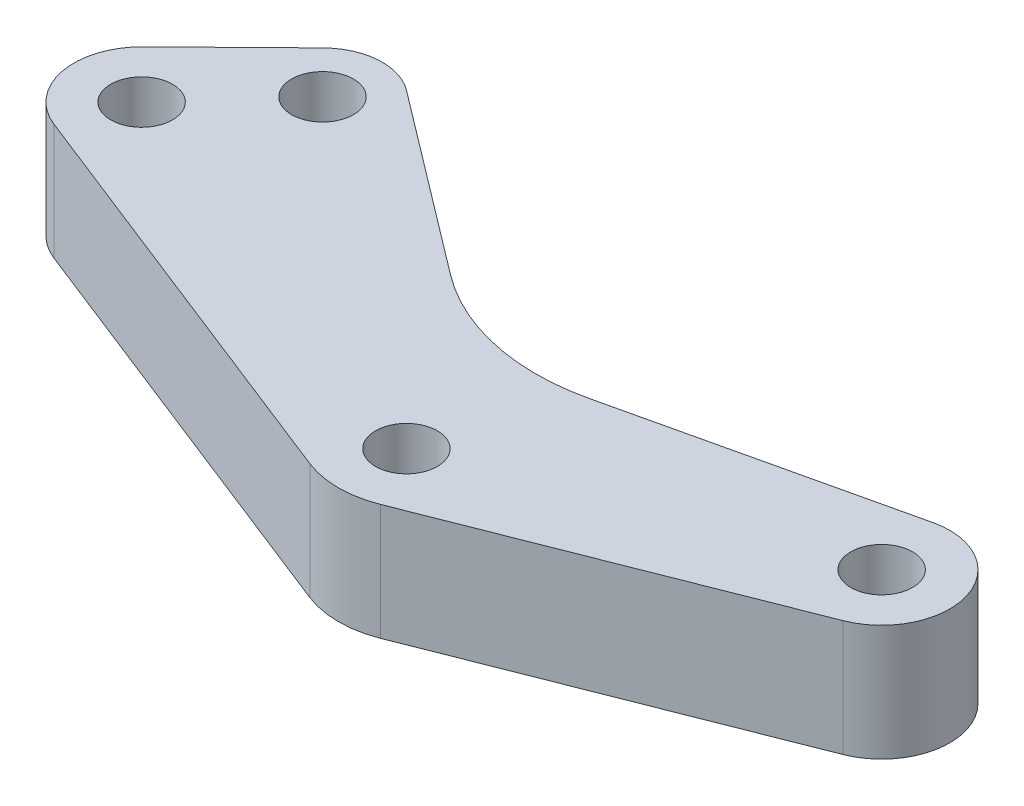
from build123d import *

# Parameters (mm, degrees)
ESBO_O1_R                  = 1.6
RESSALTO_EXTRUS_O1_DEPTH   = 6
ESBO_O5_R                  = 1.6
RESSALTO_EXTRUS_O2_DEPTH   = 6
ESBO_O2_R                  = 1.6
CORTE_EXTRUS_O1_DEPTH      = 1
CORTE_EXTRUS_O1_DEPTH_BACK = 10


with BuildPart() as part:
    # Esboço1 → Ressalto-extrusão1 (new body)
    with BuildSketch(Plane.XZ.offset(6)):
        with BuildLine():
            Line((23.658239146, -5.419790473), (1.830835365, 3.169198905))
            ThreePointArc((1.830835365, 3.169198905), (0, 3.516453278), (-1.830835365, 3.169198905))
            Line((-1.830835365, 3.169198905), (-23.658239146, -5.419790473))
            ThreePointArc((-23.658239146, -5.419790473), (-25.806836409, -7.98111819), (-24.825744035, -11.177104364))
            Line((-24.825744035, -11.177104364), (-20.101514858, -15.804403192))
            ThreePointArc((-20.101514858, -15.804403192), (-18.128320556, -16.683568025), (-16.059952818, -16.060445681))
            Line((-16.059952818, -16.060445681), (-6.643887712, -8.924606384))
            ThreePointArc((-6.643887712, -8.924606384), (0, -6.691518958), (6.643887712, -8.924606384))
            Line((6.643887712, -8.924606384), (16.059952818, -16.060445681))
            ThreePointArc((16.059952818, -16.060445681), (18.128320556, -16.683568025), (20.101514858, -15.804403192))
            Line((20.101514858, -15.804403192), (24.825744035, -11.177104364))
            ThreePointArc((24.825744035, -11.177104364), (25.806836409, -7.98111819), (23.658239146, -5.419790473))
        make_face()
        with Locations((-17.932321173, -13.589770319)):
            Circle(ESBO_O1_R, mode=Mode.SUBTRACT)
        Circle(ESBO_O1_R, mode=Mode.SUBTRACT)
        with Locations((17.932321173, -13.589770319)):
            Circle(ESBO_O1_R, mode=Mode.SUBTRACT)
        with Locations((-22.376654391, -8.676712411)):
            Circle(ESBO_O1_R, mode=Mode.SUBTRACT)
        with Locations((22.376654391, -8.676712411)):
            Circle(ESBO_O1_R, mode=Mode.SUBTRACT)
    extrude(amount=-RESSALTO_EXTRUS_O1_DEPTH)

    # Esboço5 → Ressalto-extrusão2 (add)
    with BuildSketch(Plane.XZ.offset(6)):
        with Locations((17.932321173, -13.589770319)):
            Circle(ESBO_O5_R)
        with Locations((22.376654391, -8.676712411)):
            Circle(ESBO_O5_R)
    extrude(amount=-RESSALTO_EXTRUS_O2_DEPTH)

    # Esboço2 → Corte-extrusão1 (cut, two sides)
    with BuildSketch(Plane.XZ.offset(6)) as corte_extrus_o1_sk:
        with BuildLine():
            Line((16.923117575, -10.30388989), (2.470733648, -6.972588263))
            ThreePointArc((2.470733648, -6.972588263), (4.660651706, -7.727668012), (6.643887712, -8.924606384))
            Line((6.643887712, -8.924606384), (16.059952818, -16.060445681))
            ThreePointArc((16.059952818, -16.060445681), (18.128320556, -16.683568025), (20.101514858, -15.804403192))
            Line((20.101514858, -15.804403192), (24.825744035, -11.177104364))
            ThreePointArc((24.825744035, -11.177104364), (25.806836409, -7.98111819), (23.658239146, -5.419790473))
            Line((23.658239146, -5.419790473), (19.005551183, -3.588977798))
            ThreePointArc((19.005551183, -3.588977798), (21.081563864, -7.913151406), (16.923117575, -10.30388989))
        make_face()
        with Locations((17.714851393, -6.869063992)):
            Circle(ESBO_O2_R)
    extrude(amount=CORTE_EXTRUS_O1_DEPTH, mode=Mode.SUBTRACT)
    extrude(corte_extrus_o1_sk.sketch, amount=-CORTE_EXTRUS_O1_DEPTH_BACK, mode=Mode.SUBTRACT)


solid = part.part
